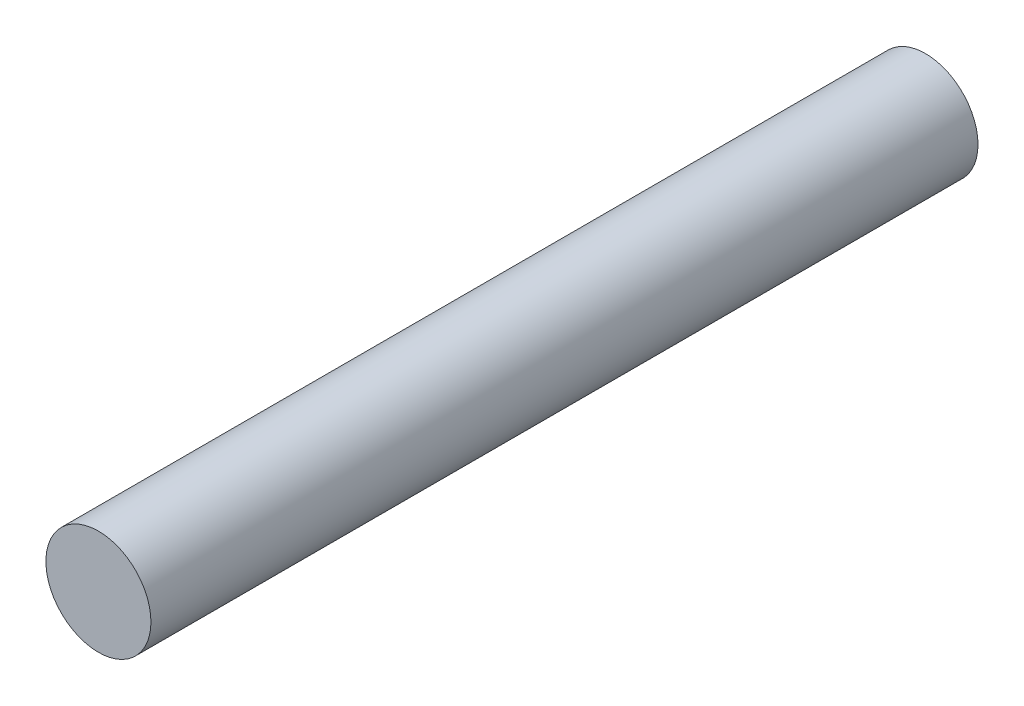
from build123d import *

# Parameters (mm, degrees)
CROQUIS1_R = 6.35


with BuildPart() as part:
    # Barrer1: sweep along a path in Croquis2
    with BuildLine(Plane(origin=(0, 0, 0), x_dir=(0, 0, -1), z_dir=(1, 0, 0))) as barrer1_path:
        Line((0, 0), (100, 0))
    # Croquis1 → Barrer1 (sweep)
    with BuildSketch(Plane.XY):
        Circle(CROQUIS1_R)
    sweep(path=barrer1_path.line)


solid = part.part
